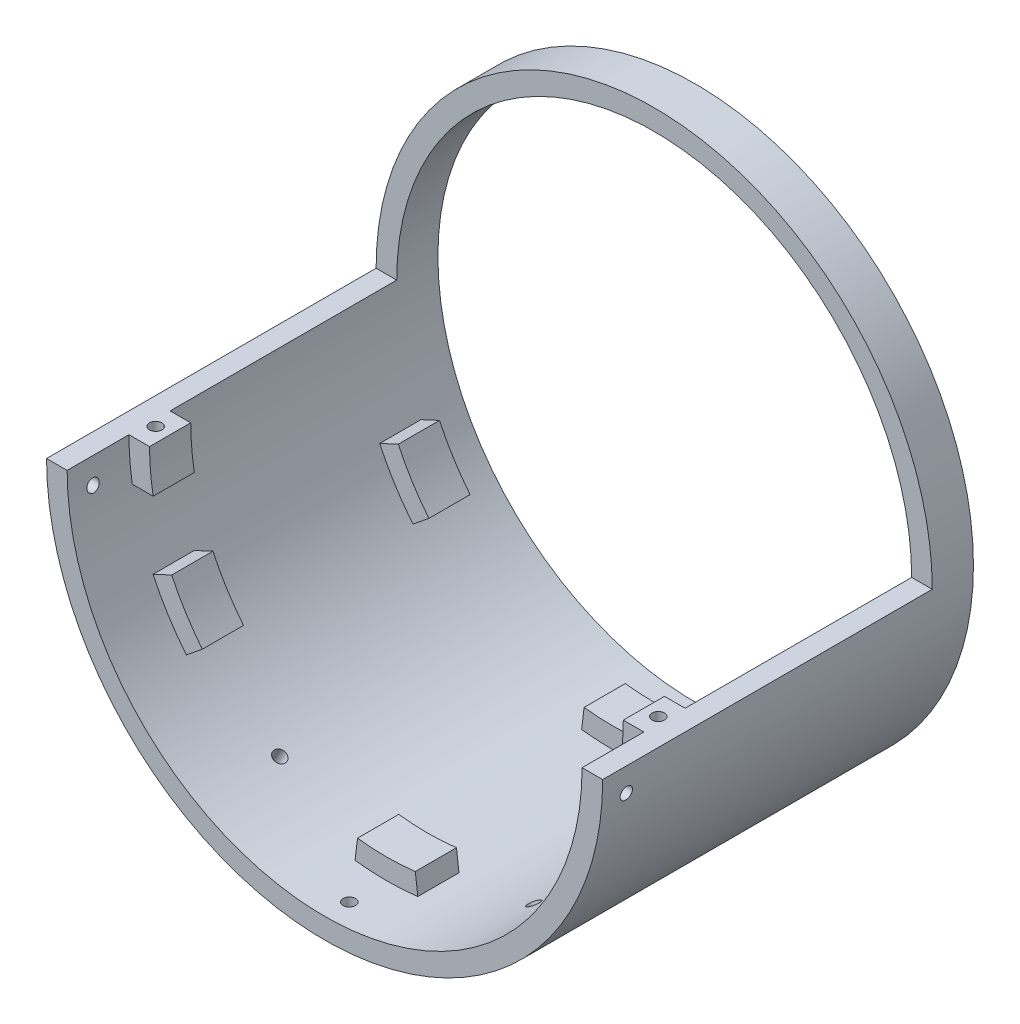
from build123d import *

# Parameters (mm, degrees)
SKETCH2_R                = 67.5
SKETCH2_R_2              = 62.5
BOSS_EXTRUDE1_DEPTH      = 10
BOSS_EXTRUDE2_DEPTH      = 80
BOSS_EXTRUDE3_DEPTH      = 10
BOSS_EXTRUDE3_2_DEPTH    = 10
BOSS_EXTRUDE3_3_DEPTH    = 10
BOSS_EXTRUDE5_DEPTH      = 10
SKETCH12_W               = 10
SKETCH12_H               = 10
BOSS_EXTRUDE6_DEPTH      = 10
SKETCH14_W               = 10
SKETCH14_H               = 10
BOSS_EXTRUDE7_DEPTH      = 10
CUT_EXTRUDE3_DEPTH       = 116.488094625
CUT_EXTRUDE3_DEPTH_BACK  = 116.488094625
SKETCH13_R               = 57.5
SKETCH17_R               = 1.5
CUT_EXTRUDE4_DEPTH       = 6
CUT_EXTRUDE5_DEPTH       = 172.91931247
CUT_EXTRUDE5_DEPTH_BACK  = 172.91931247
SKETCH19_R               = 1.5
SKETCH20_R               = 1.5
CUT_EXTRUDE8_DEPTH       = 22
CUT_EXTRUDE10_DEPTH      = 10
CUT_EXTRUDE10_DEPTH_BACK = 10
SKETCH21_R               = 1.5
CUT_EXTRUDE11_DEPTH      = 10
CUT_EXTRUDE11_DEPTH_BACK = 10
SKETCH22_R               = 1.5


with BuildPart() as part:
    # Sketch2 → Boss-Extrude1 (new body)
    with BuildSketch(Plane.XY):
        Circle(SKETCH2_R)
        Circle(SKETCH2_R_2, mode=Mode.SUBTRACT)
    extrude(amount=BOSS_EXTRUDE1_DEPTH)

    # Sketch3 → Boss-Extrude2 (add)
    with BuildSketch(Plane.XY.offset(10)):
        with BuildLine():
            Line((67.5, 0), (62.5, 0))
            ThreePointArc((62.5, 0), (0, -62.5), (-62.5, 0))
            Line((-62.5, 0), (-67.5, 0))
            ThreePointArc((-67.5, 0), (0, -67.5), (67.5, 0))
        make_face()
    extrude(amount=BOSS_EXTRUDE2_DEPTH)

    # Sketch11 → Boss-Extrude5 (add)
    with BuildSketch(Plane.XY.offset(65)):
        with BuildLine():
            Line((-52.112697755, -24.30055005), (-56.64423669, -26.413641359))
            ThreePointArc((-56.64423669, -26.413641359), (-53.00300601, -33.119954015), (-48.571622591, -39.332524441))
            Line((-48.571622591, -39.332524441), (-44.685892784, -36.185922485))
            ThreePointArc((-44.685892784, -36.185922485), (-48.762765529, -30.470357693), (-52.112697755, -24.30055005))
        make_face()
        with BuildLine():
            ThreePointArc((48.571622591, -39.332524441), (53.00300601, -33.119954015), (56.64423669, -26.413641359))
            Line((56.64423669, -26.413641359), (52.112697755, -24.30055005))
            ThreePointArc((52.112697755, -24.30055005), (48.762765529, -30.470357693), (44.685892784, -36.185922485))
            Line((44.685892784, -36.185922485), (48.571622591, -39.332524441))
        make_face()
        with BuildLine():
            Line((-7.007487246, -57.071403719), (-7.616833963, -62.034134478))
            ThreePointArc((-7.616833963, -62.034134478), (0, -62.5), (7.616833963, -62.034134478))
            Line((7.616833963, -62.034134478), (7.007487246, -57.071403719))
            ThreePointArc((7.007487246, -57.071403719), (0, -57.5), (-7.007487246, -57.071403719))
        make_face()
    extrude(amount=BOSS_EXTRUDE5_DEPTH)

    # Sketch12 → Boss-Extrude6 (add)
    with BuildSketch(Plane.ZY.offset(-62.5)):
        with Locations((70, -5)):
            Rectangle(SKETCH12_W, SKETCH12_H)
    extrude(amount=BOSS_EXTRUDE6_DEPTH)

    # Sketch14 → Boss-Extrude7 (add)
    with BuildSketch(Plane(origin=(-62.5, 0, 0), x_dir=(0, 0, -1), z_dir=(1, 0, 0))):
        with Locations((-70, -5)):
            Rectangle(SKETCH14_W, SKETCH14_H)
    extrude(amount=BOSS_EXTRUDE7_DEPTH)

    # Sketch13 → Cut-Extrude3 (cut, two sides: drawn at the far end of the back side and taken through both)
    with BuildSketch(Plane.XY.offset(65).offset(-CUT_EXTRUDE3_DEPTH_BACK)):
        Circle(SKETCH13_R)
    extrude(amount=CUT_EXTRUDE3_DEPTH + CUT_EXTRUDE3_DEPTH_BACK, mode=Mode.SUBTRACT)

    # Sketch17 → Cut-Extrude4 (cut)
    with BuildSketch(Plane(origin=(0, 0, 0), x_dir=(1, 0, 0), z_dir=(0, 1, 0))):
        with Locations((61, -70)):
            Circle(SKETCH17_R)
        with Locations((-61, -70)):
            Circle(SKETCH17_R)
    extrude(amount=-CUT_EXTRUDE4_DEPTH, mode=Mode.SUBTRACT)

    # Sketch19 → Cut-Extrude5 (cut, two sides: drawn at the far end of the back side and taken through both)
    with BuildSketch(Plane.ZY.offset(-62.5).offset(-CUT_EXTRUDE5_DEPTH_BACK)):
        with Locations((84, -6)):
            Circle(SKETCH19_R)
    extrude(amount=CUT_EXTRUDE5_DEPTH + CUT_EXTRUDE5_DEPTH_BACK, mode=Mode.SUBTRACT)

    # Sketch20 → Cut-Extrude8 (cut, symmetric)
    with BuildSketch(Plane(origin=(0, -62.5, 0), x_dir=(1, 0, 0), z_dir=(0, 1, 0))):
        with Locations((0, -84)):
            Circle(SKETCH20_R)
    extrude(amount=CUT_EXTRUDE8_DEPTH, both=True, mode=Mode.SUBTRACT)

    # Sketch21 → Cut-Extrude10 (cut, two sides: drawn at the far end of the back side and taken through both)
    with BuildSketch(Plane(origin=(-30.300601265, -54.663731696, 0), x_dir=(0.8746197071393954, -0.48480962024633784, 0), z_dir=(0.4848096202463379, 0.8746197071393954, 0)).offset(-CUT_EXTRUDE10_DEPTH_BACK)):
        with Locations((-0.663731696, -70)):
            Circle(SKETCH21_R)
    extrude(amount=CUT_EXTRUDE10_DEPTH + CUT_EXTRUDE10_DEPTH_BACK, mode=Mode.SUBTRACT)

    # Sketch22 → Cut-Extrude11 (cut, two sides: drawn at the far end of the back side and taken through both)
    with BuildSketch(Plane(origin=(30.300601265, -54.663731696, 0), x_dir=(0.8746197071393965, 0.4848096202463359, 0), z_dir=(-0.48480962024633584, 0.8746197071393964, 0)).offset(-CUT_EXTRUDE11_DEPTH_BACK)):
        with Locations((0.539879121, -70)):
            Circle(SKETCH22_R)
    extrude(amount=CUT_EXTRUDE11_DEPTH + CUT_EXTRUDE11_DEPTH_BACK, mode=Mode.SUBTRACT)


with BuildPart() as body_2:
    # Sketch6 → Boss-Extrude3 (new body)
    with BuildSketch(Plane.XY.offset(10)):
        with BuildLine():
            Line((-52.112697755, -24.30055005), (-56.64423669, -26.413641359))
            ThreePointArc((-56.64423669, -26.413641359), (-53.00300601, -33.119954015), (-48.571622591, -39.332524441))
            Line((-48.571622591, -39.332524441), (-44.685892784, -36.185922485))
            ThreePointArc((-44.685892784, -36.185922485), (-48.762765529, -30.470357693), (-52.112697755, -24.30055005))
        make_face()
    extrude(amount=BOSS_EXTRUDE3_DEPTH)


with BuildPart() as body_3:
    # Sketch6 → Boss-Extrude3 2 (new body)
    with BuildSketch(Plane.XY.offset(10)):
        with BuildLine():
            ThreePointArc((48.571622591, -39.332524441), (53.00300601, -33.119954015), (56.64423669, -26.413641359))
            Line((56.64423669, -26.413641359), (52.112697755, -24.30055005))
            ThreePointArc((52.112697755, -24.30055005), (48.762765529, -30.470357693), (44.685892784, -36.185922485))
            Line((44.685892784, -36.185922485), (48.571622591, -39.332524441))
        make_face()
    extrude(amount=BOSS_EXTRUDE3_2_DEPTH)


with BuildPart() as body_4:
    # Sketch6 → Boss-Extrude3 3 (new body)
    with BuildSketch(Plane.XY.offset(10)):
        with BuildLine():
            Line((-7.007487246, -57.071403719), (-7.616833963, -62.034134478))
            ThreePointArc((-7.616833963, -62.034134478), (0, -62.5), (7.616833963, -62.034134478))
            Line((7.616833963, -62.034134478), (7.007487246, -57.071403719))
            ThreePointArc((7.007487246, -57.071403719), (0, -57.5), (-7.007487246, -57.071403719))
        make_face()
    extrude(amount=BOSS_EXTRUDE3_3_DEPTH)


solid = Compound([part.part, body_2.part, body_3.part, body_4.part])
